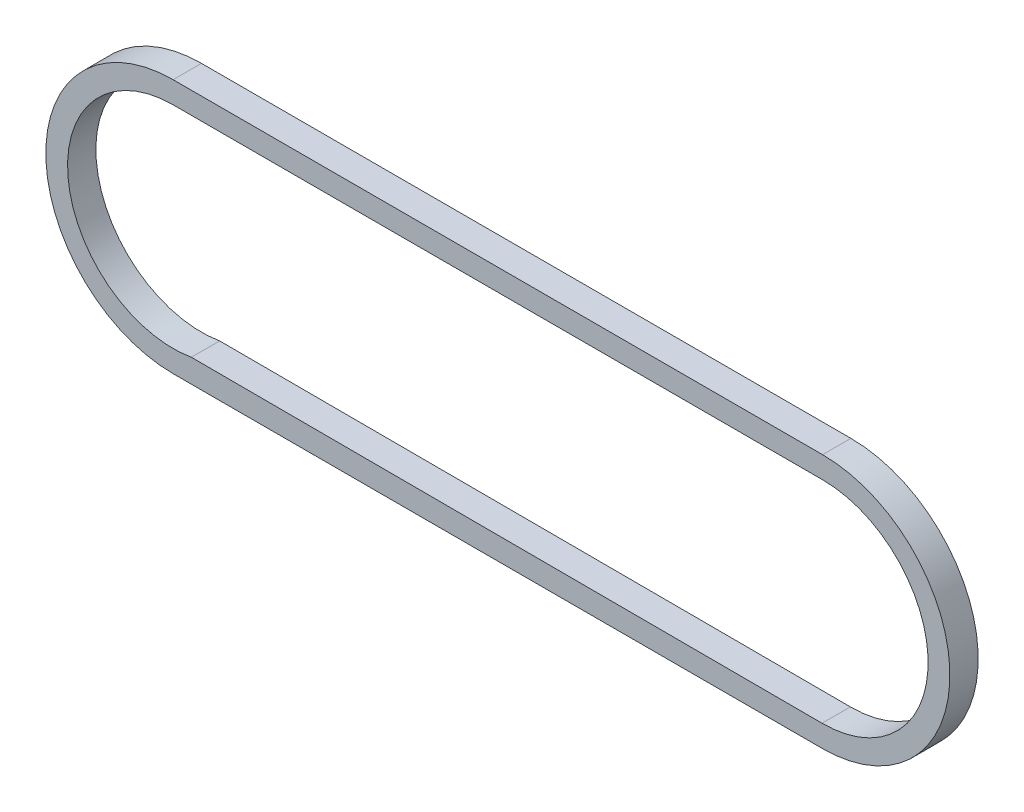
from build123d import *

# Parameters (mm, degrees)
DODANIE_WYCI_GNI_CIE1_DEPTH      = 1
DODANIE_WYCI_GNI_CIE1_DEPTH_BACK = 9.9


with BuildPart() as part:
    # Szkic1 → Dodanie-wyciągnięcie1 (new body, two sides)
    with BuildSketch(Plane.XY) as dodanie_wyci_gni_cie1_sk:
        with BuildLine():
            Line((-250, -49), (0, -49))
            ThreePointArc((0, -49), (49, 0), (0, 49))
            Line((0, 49), (-250, 49))
            ThreePointArc((-250, 49), (-299, 0), (-250, -49))
        make_face()
        with BuildLine():
            ThreePointArc((0, 40.63), (40.63, 0), (0, -40.63))
            Line((0, -40.63), (-0.2047739, -40.62948397))
            Line((-0.2047739, -40.62948397), (-242.972914826, -40.017708255))
            ThreePointArc((-242.972914826, -40.017708255), (-290.476637622, -3.526855087), (-250, 40.63))
            Line((-250, 40.63), (0, 40.63))
        make_face(mode=Mode.SUBTRACT)
    extrude(amount=DODANIE_WYCI_GNI_CIE1_DEPTH)
    extrude(dodanie_wyci_gni_cie1_sk.sketch, amount=-DODANIE_WYCI_GNI_CIE1_DEPTH_BACK)


solid = part.part
